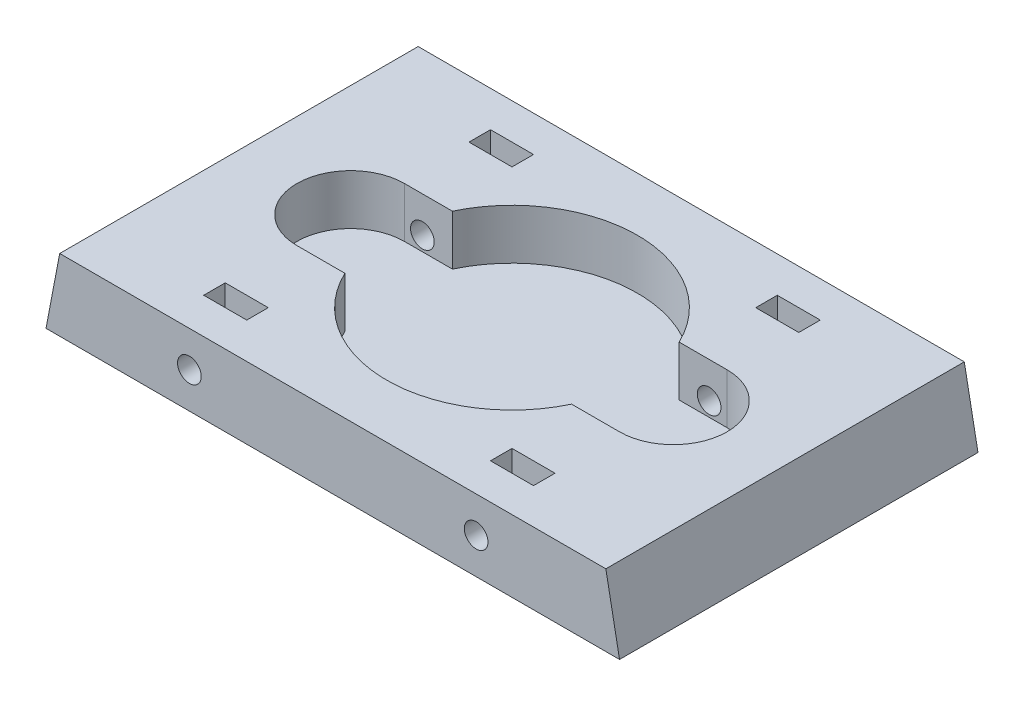
from build123d import *

# Parameters (mm, degrees)
SKETCH1_W               = 80
SKETCH1_H               = 50
BOSS_EXTRUDE1_DEPTH     = 5
SKETCH3_R               = 1.65
CUT_EXTRUDE1_DEPTH      = 5
CUT_EXTRUDE2_DEPTH      = 3
SKETCH5_R               = 1.65
CUT_EXTRUDE3_DEPTH      = 10
MIRROR2_COPY_1_SKETCH_R = 1.65
MIRROR2_COPY_1_DEPTH    = 5
MIRROR2_COPY_2_DEPTH    = 3
MIRROR2_COPY_3_SKETCH_R = 1.65
MIRROR2_COPY_3_DEPTH    = 10
CUT_EXTRUDE4_DEPTH      = 51
SKETCH7_R               = 17.5
CUT_EXTRUDE5_DEPTH      = 7
CUT_EXTRUDE6_DEPTH      = 7


with BuildPart() as part:
    # Sketch1 → Boss-Extrude1 (new body, symmetric)
    with BuildSketch(Plane(origin=(0, 0, 0), x_dir=(1, 0, 0), z_dir=(0, 1, 0))):
        Rectangle(SKETCH1_W, SKETCH1_H)
    extrude(amount=BOSS_EXTRUDE1_DEPTH, both=True)

    # Sketch3 → Cut-Extrude1 (cut)
    with BuildSketch(Plane.XY.offset(25)):
        with Locations((-20, 0)):
            Circle(SKETCH3_R)
    cut_extrude1 = extrude(amount=-CUT_EXTRUDE1_DEPTH, mode=Mode.SUBTRACT)

    # Sketch4 → Cut-Extrude2 (cut)
    with BuildSketch(Plane.XY.offset(20)):
        Polygon((-23, 1.732050808), (-23, 5.757498214), (-17, 5.757498214), (-17, 1.732050808), (-17, -1.732050808), (-20, -3.464101615), (-23, -1.732050808), align=None)
    cut_extrude2 = extrude(amount=-CUT_EXTRUDE2_DEPTH, mode=Mode.SUBTRACT)

    # Sketch5 → Cut-Extrude3 (cut)
    with BuildSketch(Plane.XY.offset(17)):
        with Locations((-20, 0)):
            Circle(SKETCH5_R)
    cut_extrude3 = extrude(amount=-CUT_EXTRUDE3_DEPTH, mode=Mode.SUBTRACT)

    # Mirror1: Cut-Extrude1, Cut-Extrude2, Cut-Extrude3 across plane
    add(cut_extrude1.mirror(Plane(origin=(0, 0, 0), x_dir=(0, 0, 1), z_dir=(1, 0, 0))), mode=Mode.SUBTRACT)
    add(cut_extrude2.mirror(Plane(origin=(0, 0, 0), x_dir=(0, 0, 1), z_dir=(1, 0, 0))), mode=Mode.SUBTRACT)
    add(cut_extrude3.mirror(Plane(origin=(0, 0, 0), x_dir=(0, 0, 1), z_dir=(1, 0, 0))), mode=Mode.SUBTRACT)

    # Mirror2: Cut-Extrude1, Cut-Extrude2, Cut-Extrude3 across plane
    add(cut_extrude1.mirror(Plane.XY), mode=Mode.SUBTRACT)
    add(cut_extrude2.mirror(Plane.XY), mode=Mode.SUBTRACT)
    add(cut_extrude3.mirror(Plane.XY), mode=Mode.SUBTRACT)

    # Mirror2 copy 1 sketch → Mirror2 copy 1 (cut)
    with BuildSketch(Plane(origin=(0, 0, -25), x_dir=(-1, 0, 0), z_dir=(0, 0, -1))):
        with Locations((-20, 0)):
            Circle(MIRROR2_COPY_1_SKETCH_R)
    extrude(amount=-MIRROR2_COPY_1_DEPTH, mode=Mode.SUBTRACT)

    # Mirror2 copy 2 sketch → Mirror2 copy 2 (cut)
    with BuildSketch(Plane(origin=(0, 0, -20), x_dir=(-1, 0, 0), z_dir=(0, 0, -1))):
        Polygon((-23, 1.732050808), (-23, 5.757498214), (-17, 5.757498214), (-17, 1.732050808), (-17, -1.732050808), (-20, -3.464101615), (-23, -1.732050808), align=None)
    extrude(amount=-MIRROR2_COPY_2_DEPTH, mode=Mode.SUBTRACT)

    # Mirror2 copy 3 sketch → Mirror2 copy 3 (cut)
    with BuildSketch(Plane(origin=(0, 0, -17), x_dir=(-1, 0, 0), z_dir=(0, 0, -1))):
        with Locations((-20, 0)):
            Circle(MIRROR2_COPY_3_SKETCH_R)
    extrude(amount=-MIRROR2_COPY_3_DEPTH, mode=Mode.SUBTRACT)

    # Sketch6 → Cut-Extrude4 (cut, through all)
    with BuildSketch(Plane.XY.offset(25)):
        Polygon((-40, 5), (-38.09, 5), (-40, -5), align=None)
    cut_extrude4 = extrude(amount=-CUT_EXTRUDE4_DEPTH, mode=Mode.SUBTRACT)

    # Mirror3: Cut-Extrude4 across plane
    add(cut_extrude4.mirror(Plane(origin=(0, 0, 0), x_dir=(0, 0, 1), z_dir=(1, 0, 0))), mode=Mode.SUBTRACT)

    # Sketch7 → Cut-Extrude5 (cut)
    with BuildSketch(Plane(origin=(0, 5, 0), x_dir=(1, 0, 0), z_dir=(0, 1, 0))):
        Circle(SKETCH7_R)
    extrude(amount=-CUT_EXTRUDE5_DEPTH, mode=Mode.SUBTRACT)

    # Sketch8 → Cut-Extrude6 (cut)
    with BuildSketch(Plane(origin=(0, 5, 0), x_dir=(1, 0, 0), z_dir=(0, 1, 0))):
        with BuildLine():
            Line((22.5, -7.5), (-22.5, -7.5))
            ThreePointArc((-22.5, -7.5), (-30, 0), (-22.5, 7.5))
            Line((-22.5, 7.5), (22.5, 7.5))
            ThreePointArc((22.5, 7.5), (30, 0), (22.5, -7.5))
        make_face()
    extrude(amount=-CUT_EXTRUDE6_DEPTH, mode=Mode.SUBTRACT)


solid = part.part
